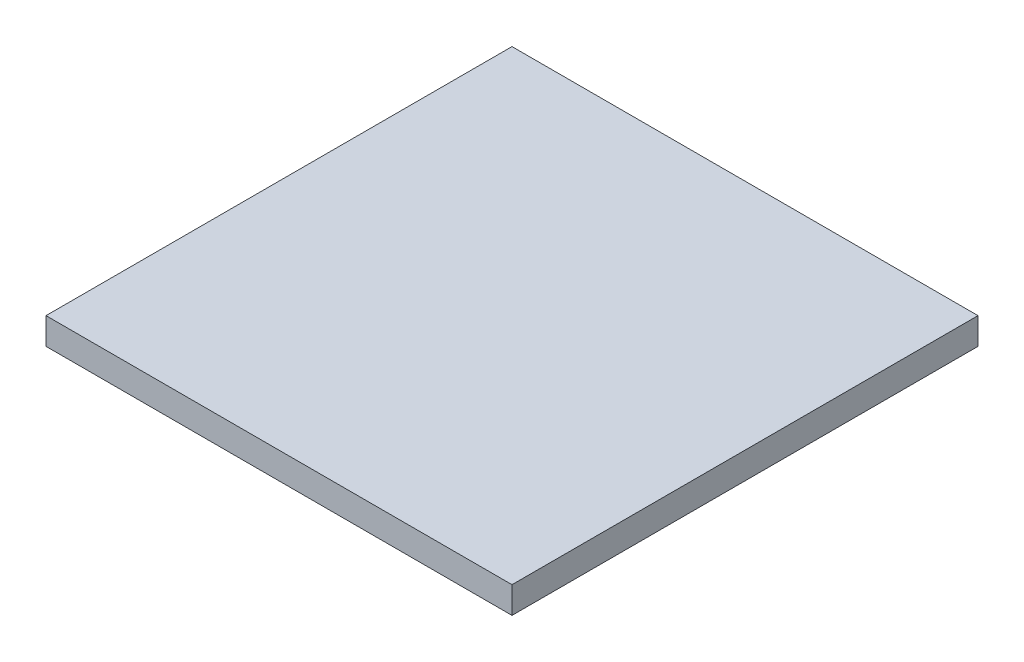
from build123d import *

# Parameters (mm, degrees)
SKETCH1_W           = 7
SKETCH1_H           = 7
BOSS_EXTRUDE1_DEPTH = 0.4


with BuildPart() as part:
    # Sketch1 → Boss-Extrude1 (new body)
    with BuildSketch(Plane(origin=(0, 0, 0), x_dir=(1, 0, 0), z_dir=(0, 1, 0))):
        Rectangle(SKETCH1_W, SKETCH1_H)
    extrude(amount=BOSS_EXTRUDE1_DEPTH)


solid = part.part
